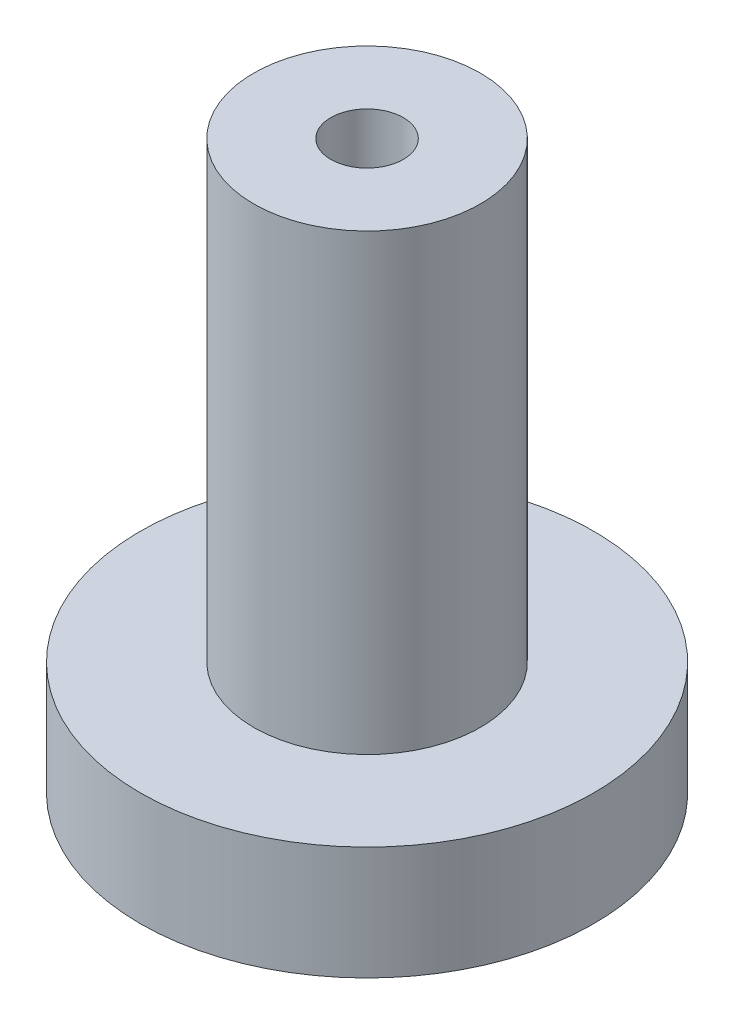
from build123d import *

# Parameters (mm, degrees)
SKETCH1_R           = 12.7
BOSS_EXTRUDE1_DEPTH = 6.35
SKETCH2_R           = 6.35
BOSS_EXTRUDE2_DEPTH = 25.4
SKETCH3_R           = 2.032
CUT_EXTRUDE1_DEPTH  = 5.588


with BuildPart() as part:
    # Sketch1 → Boss-Extrude1 (new body)
    with BuildSketch(Plane(origin=(0, 0, 0), x_dir=(1, 0, 0), z_dir=(0, 1, 0))):
        Circle(SKETCH1_R)
    extrude(amount=BOSS_EXTRUDE1_DEPTH)

    # Sketch2 → Boss-Extrude2 (add)
    with BuildSketch(Plane(origin=(0, 6.35, 0), x_dir=(1, 0, 0), z_dir=(0, 1, 0))):
        Circle(SKETCH2_R)
    extrude(amount=BOSS_EXTRUDE2_DEPTH)

    # Sketch3 → Cut-Extrude1 (cut)
    with BuildSketch(Plane(origin=(0, 31.75, 0), x_dir=(1, 0, 0), z_dir=(0, 1, 0))):
        Circle(SKETCH3_R)
    extrude(amount=-CUT_EXTRUDE1_DEPTH, mode=Mode.SUBTRACT)


solid = part.part
